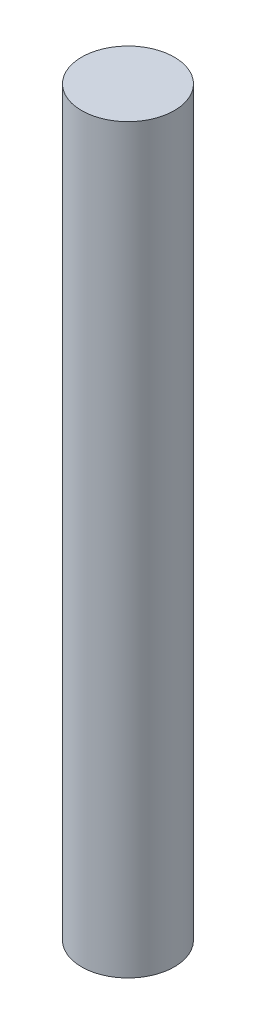
from build123d import *

# Parameters (mm, degrees)
SKETCH1_R           = 1.5875
BOSS_EXTRUDE1_DEPTH = 25.4


with BuildPart() as part:
    # Sketch1 → Boss-Extrude1 (new body)
    with BuildSketch(Plane(origin=(0, 0, 0), x_dir=(1, 0, 0), z_dir=(0, 1, 0))):
        Circle(SKETCH1_R)
    extrude(amount=BOSS_EXTRUDE1_DEPTH)


solid = part.part
